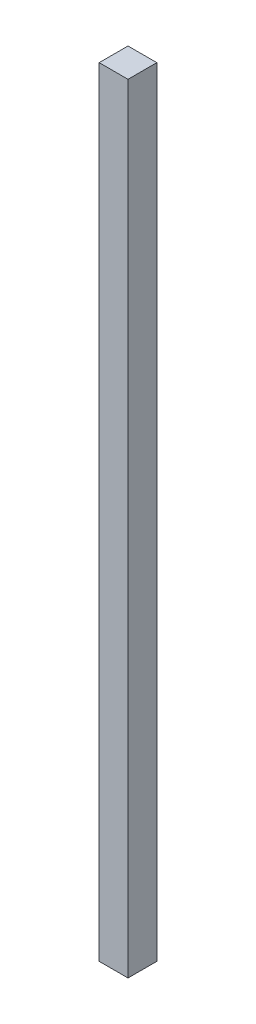
from build123d import *

# Parameters (mm, degrees)
SKETCH1_W           = 25.4
SKETCH1_H           = 25.4
BOSS_EXTRUDE1_DEPTH = 685.8


with BuildPart() as part:
    # Sketch1 → Boss-Extrude1 (new body)
    with BuildSketch(Plane(origin=(0, 0, 0), x_dir=(1, 0, 0), z_dir=(0, 1, 0))):
        with Locations((12.7, 12.7)):
            Rectangle(SKETCH1_W, SKETCH1_H)
    extrude(amount=BOSS_EXTRUDE1_DEPTH)


solid = part.part
